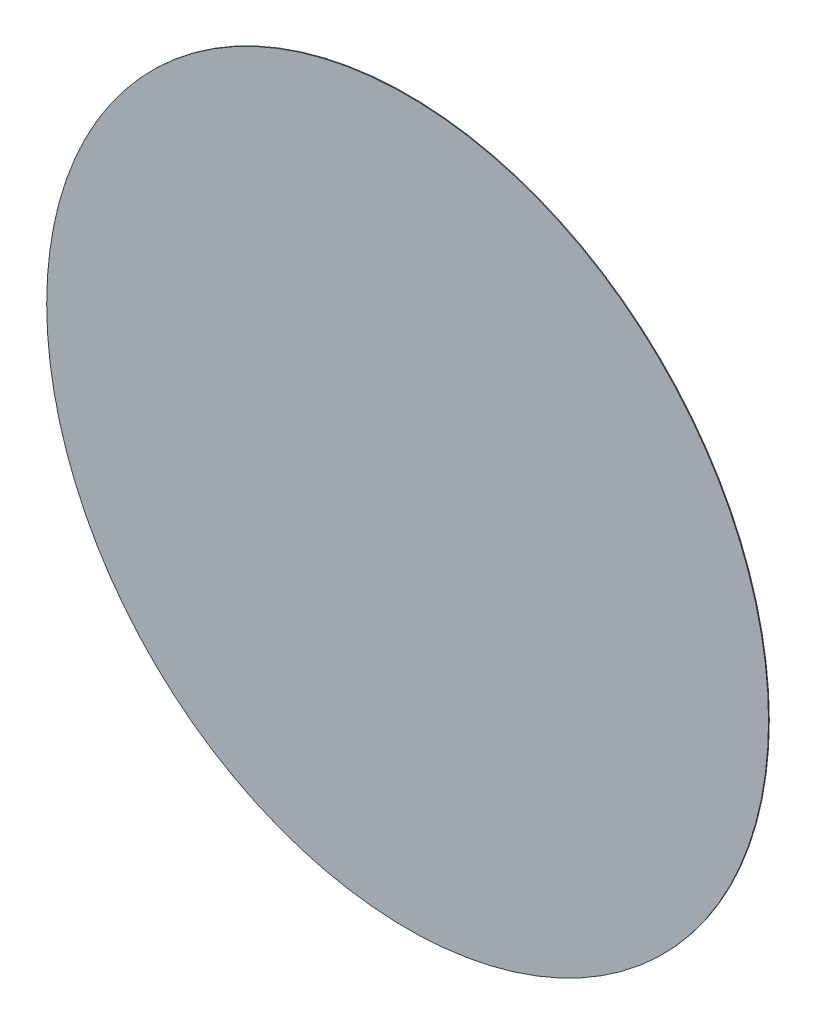
from build123d import *

# Parameters (mm, degrees)
SKETCH1_R           = 4.75
BOSS_EXTRUDE1_DEPTH = 0.01


with BuildPart() as part:
    # Sketch1 → Boss-Extrude1 (new body)
    with BuildSketch(Plane.XY):
        Circle(SKETCH1_R)
    extrude(amount=BOSS_EXTRUDE1_DEPTH)


solid = part.part
